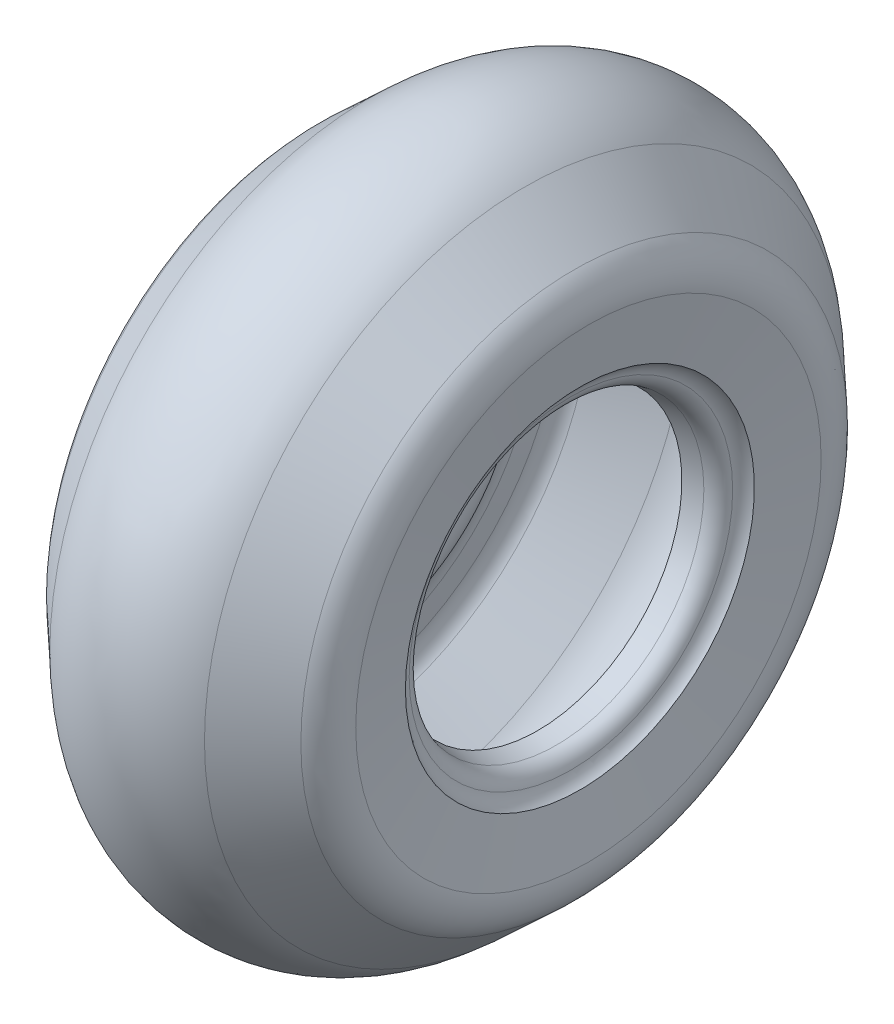
from build123d import *


with BuildPart() as part:
    # Sketch3 → Revolve2 (revolve)
    with BuildSketch(Plane(origin=(0, 0, 0), x_dir=(1, 0, 0), z_dir=(0, 1, 0))):
        with BuildLine():
            Line((-64.359504334, -266.242118641), (-105.8736083, -227.529590405))
            ThreePointArc((-105.8736083, -227.529590405), (-115.971141664, -212.075828194), (-117.73475, -193.70006611))
            Line((-117.73475, -193.70006611), (-110.6175, -145.25131611))
            ThreePointArc((-110.6175, -145.25131611), (-105.845919074, -140.683151583), (-103.154901682, -134.650363084))
            ThreePointArc((-103.154901682, -134.650363084), (-98.780541633, -126.951627685), (-90.895, -122.923751603))
            Line((-90.895, -122.923751603), (-75.46, -120.094001603))
            ThreePointArc((-75.46, -120.094001603), (-79.229903863, -135.549215216), (-87.8423, -148.924656731))
            ThreePointArc((-87.8423, -148.924656731), (-97.275191012, -162.754830344), (-102.521721628, -178.652221686))
            Line((-102.521721628, -178.652221686), (-106.630125, -201.375971686))
            ThreePointArc((-106.630125, -201.375971686), (-105.863989679, -212.159594802), (-100.025472362, -221.258232413))
            Line((-100.025472362, -221.258232413), (-58.511368397, -259.970760649))
            ThreePointArc((-58.511368397, -259.970760649), (0, -283.019001603), (58.511368397, -259.970760649))
            Line((58.511368397, -259.970760649), (100.025472362, -221.258232413))
            ThreePointArc((100.025472362, -221.258232413), (105.863989679, -212.159594802), (106.630125, -201.375971686))
            Line((106.630125, -201.375971686), (102.521721628, -178.652221686))
            ThreePointArc((102.521721628, -178.652221686), (97.275191012, -162.754830344), (87.8423, -148.924656731))
            ThreePointArc((87.8423, -148.924656731), (79.229903863, -135.549215216), (75.46, -120.094001603))
            Line((75.46, -120.094001603), (90.895, -122.923751603))
            ThreePointArc((90.895, -122.923751603), (98.780541633, -126.951627685), (103.154901682, -134.650363084))
            ThreePointArc((103.154901682, -134.650363084), (105.845919074, -140.683151583), (110.6175, -145.25131611))
            Line((110.6175, -145.25131611), (117.73475, -193.70006611))
            ThreePointArc((117.73475, -193.70006611), (115.971141664, -212.075828194), (105.8736083, -227.529590405))
            Line((105.8736083, -227.529590405), (64.359504334, -266.242118641))
            ThreePointArc((64.359504334, -266.242118641), (0, -291.594001603), (-64.359504334, -266.242118641))
        make_face()
    revolve(axis=Axis((0, 0, 0), (1, 0, 0)))


solid = part.part
